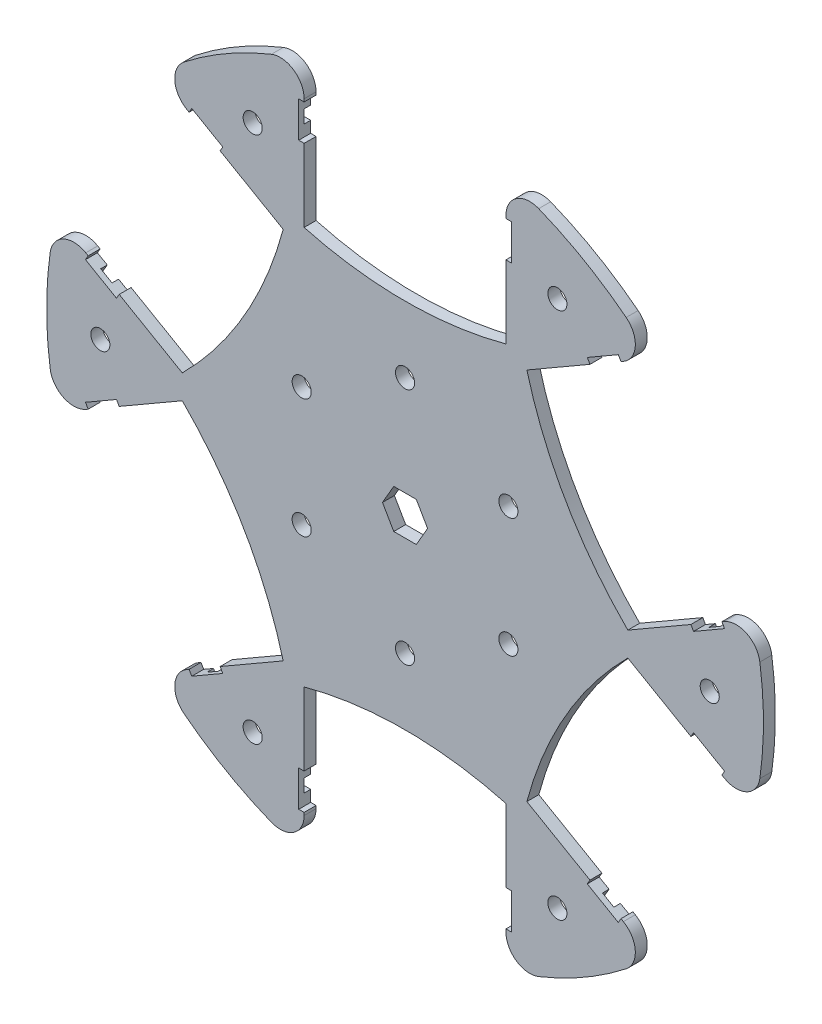
from build123d import *

# Parameters (mm, degrees)
SKETCH3_R                = 60.062756644
DISK_DEPTH               = 2
SKETCH4_W                = 50.4
SKETCH4_H                = 2.2
AXLE_DEPTH               = 1.1
ROLLER_REACH             = 86.965
WASHER_REACH             = 86.965
FILLET1_R                = 4
CIRPATTERN1_COUNT        = 6
FILLET1_OF_CIRPATTERN1_R = 4
ROLLER_SCREW_REACH       = 84.155
SKETCH9_R                = 1.6
CIRPATTERN3_COUNT        = 6
HEX_AXLE_REACH           = 84.155
HUB_SCREWS_REACH         = 84.155
SKETCH11_R               = 1.6
CIRPATTERN4_COUNT        = 6


with BuildPart() as part:
    # Sketch3 → Disk (new body)
    with BuildSketch(Plane.XY):
        Circle(SKETCH3_R)
    extrude(amount=DISK_DEPTH)

    # Sketch4 → Axle (cut)
    with BuildSketch(Plane.XY):
        with Locations((0, 48.55177146)):
            Rectangle(SKETCH4_W, SKETCH4_H)
    axle = extrude(amount=AXLE_DEPTH, mode=Mode.SUBTRACT)

    # Sketch7 → Roller (cut, up to next)
    with BuildSketch(Plane.XY, mode=Mode.PRIVATE) as roller_sk1:
        with BuildLine():
            Line((16.912362698, 62.893833964), (-16.912362698, 62.893833964))
            Line((-16.912362698, 62.893833964), (-16.912362698, 33.342312944))
            ThreePointArc((-16.912362698, 33.342312944), (0, 31.103542919), (16.912362698, 33.342312944))
            Line((16.912362698, 33.342312944), (16.912362698, 62.893833964))
        make_face()
    roller_tool1 = extrude(roller_sk1.sketch, amount=ROLLER_REACH, mode=Mode.PRIVATE) & part.part
    roller = roller_tool1.solids().sort_by_distance((0, 47.36207, 0))[0]
    add(roller, mode=Mode.SUBTRACT)

    # Sketch8 → Washer (cut, up to next)
    with BuildSketch(Plane.XY, mode=Mode.PRIVATE) as washer_sk1:
        Polygon((-17.812362698, 51.55177146), (-16.912362698, 51.55177146), (-16.412362698, 51.55177146), (-16.412362698, 45.55177146), (-16.912362698, 45.55177146), (-17.812362698, 45.55177146), align=None)
    washer_tool1 = extrude(washer_sk1.sketch, amount=WASHER_REACH, mode=Mode.PRIVATE) & part.part
    # Sketch8 → Washer (cut, up to next)
    with BuildSketch(Plane.XY, mode=Mode.PRIVATE) as washer_sk2:
        Polygon((17.812362698, 51.55177146), (17.812362698, 45.55177146), (16.912362698, 45.55177146), (16.412362698, 45.55177146), (16.412362698, 51.55177146), (16.912362698, 51.55177146), align=None)
    washer_tool2 = extrude(washer_sk2.sketch, amount=WASHER_REACH, mode=Mode.PRIVATE) & part.part
    washer_1 = washer_tool1.solids().sort_by_distance((-17.112363, 48.551771, 0))[0]
    add(washer_1, mode=Mode.SUBTRACT)
    washer_2 = washer_tool2.solids().sort_by_distance((17.112363, 48.551771, 0))[0]
    add(washer_2, mode=Mode.SUBTRACT)
    washer = washer_1 + washer_2  # Washer as one shape, for the pattern or mirror that repeats it

    # Fillet1
    fillet1_edges = [part.edges().sort_by_distance(p)[0] for p in [
        (16.912362698, 57.632514466, 1),
        (-16.912362698, 57.632514466, 1),
    ]]
    fillet(fillet1_edges, radius=FILLET1_R)

    # CirPattern1: Axle, Roller, Washer ×6 about axis
    cirpattern1_axis = Axis((0, 0, -6.491701274), (0, 0, 1))
    add([axle.rotate(cirpattern1_axis, i * 360 / CIRPATTERN1_COUNT) for i in range(1, CIRPATTERN1_COUNT)], mode=Mode.SUBTRACT)
    add([roller.rotate(cirpattern1_axis, i * 360 / CIRPATTERN1_COUNT) for i in range(1, CIRPATTERN1_COUNT)], mode=Mode.SUBTRACT)
    add([washer.rotate(cirpattern1_axis, i * 360 / CIRPATTERN1_COUNT) for i in range(1, CIRPATTERN1_COUNT)], mode=Mode.SUBTRACT)

    # Fillet1 of CirPattern1
    fillet1_of_cirpattern1_edges = [part.edges().sort_by_distance(p)[0] for p in [
        (-41.455040262, 43.462792967, 1),
        (-58.36740296, 14.169721499, 1),
        (-58.36740296, -14.169721499, 1),
        (-41.455040262, -43.462792967, 1),
        (-16.912362698, -57.632514466, 1),
        (16.912362698, -57.632514466, 1),
        (41.455040262, -43.462792967, 1),
        (58.36740296, -14.169721499, 1),
        (58.36740296, 14.169721499, 1),
        (41.455040262, 43.462792967, 1),
    ]]
    fillet(fillet1_of_cirpattern1_edges, radius=FILLET1_OF_CIRPATTERN1_R)

    # Sketch9 → Roller screw (cut, up to next)
    with BuildSketch(Plane.XY.offset(2), mode=Mode.PRIVATE) as roller_screw_sk1:
        with Locations((-25.531378322, -44.221644441)):
            Circle(SKETCH9_R)
    roller_screw_tool1 = extrude(roller_screw_sk1.sketch, amount=-ROLLER_SCREW_REACH, mode=Mode.PRIVATE) & part.part
    roller_screw = roller_screw_tool1.solids().sort_by_distance((-25.531378, -44.221644, 2))[0]
    add(roller_screw, mode=Mode.SUBTRACT)

    # CirPattern3: Roller screw ×6 about axis
    cirpattern3_axis = Axis((0, 0, -6.491701274), (0, 0, 1))
    for i in range(1, CIRPATTERN3_COUNT):
        add(roller_screw.rotate(cirpattern3_axis, i * 360 / CIRPATTERN3_COUNT), mode=Mode.SUBTRACT)

    # Sketch10 → Hex axle (cut, up to next)
    with BuildSketch(Plane.XY, mode=Mode.PRIVATE) as hex_axle_sk1:
        Polygon((3.781644263, 0), (1.890822132, 3.275), (-1.890822132, 3.275), (-3.781644263, 0), (-1.890822132, -3.275), (1.890822132, -3.275), align=None)
    hex_axle_tool1 = extrude(hex_axle_sk1.sketch, amount=HEX_AXLE_REACH, mode=Mode.PRIVATE) & part.part
    add(hex_axle_tool1.solids().sort_by_distance((0, 0, 0))[0], mode=Mode.SUBTRACT)

    # Sketch11 → Hub screws (cut, up to next)
    with BuildSketch(Plane.XY, mode=Mode.PRIVATE) as hub_screws_sk1:
        with Locations((0, 20)):
            Circle(SKETCH11_R)
    hub_screws_tool1 = extrude(hub_screws_sk1.sketch, amount=HUB_SCREWS_REACH, mode=Mode.PRIVATE) & part.part
    hub_screws = hub_screws_tool1.solids().sort_by_distance((0, 20, 0))[0]
    add(hub_screws, mode=Mode.SUBTRACT)

    # CirPattern4: Hub screws ×6 about axis
    cirpattern4_axis = Axis((0, 0, -6.491701274), (0, 0, 1))
    for i in range(1, CIRPATTERN4_COUNT):
        add(hub_screws.rotate(cirpattern4_axis, i * 360 / CIRPATTERN4_COUNT), mode=Mode.SUBTRACT)


solid = part.part
